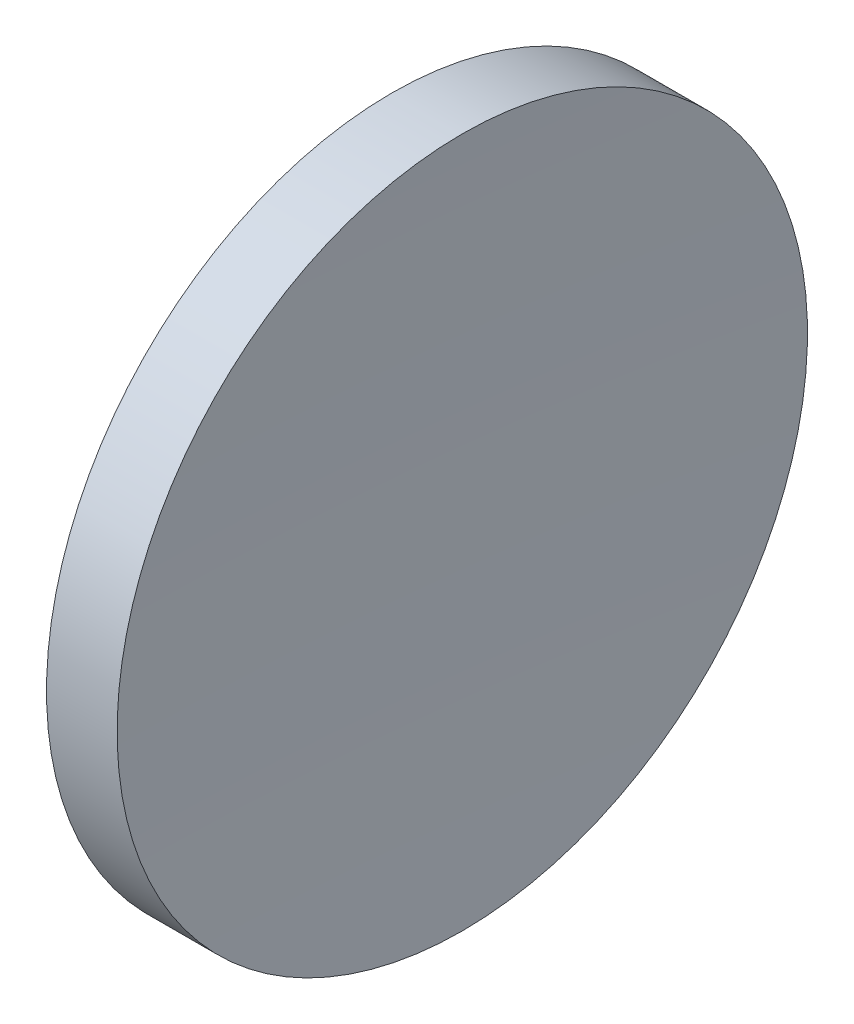
from build123d import *


with BuildPart() as part:
    # 草图1 → 旋转1 (revolve)
    with BuildSketch(Plane.XY):
        with BuildLine():
            Line((123.311924157, 77.716840471), (125.868954418, 77.716840471))
            ThreePointArc((125.868954418, 77.716840471), (125.676390648, 71.468158853), (125.612193698, 65.216840471))
            Line((125.612193698, 65.216840471), (122.612193698, 65.216840471))
            ThreePointArc((122.612193698, 65.216840471), (122.78726314, 71.476625266), (123.311924157, 77.716840471))
        make_face()
    revolve(axis=Axis((115.944491298, 65.216840471, 0), (1, 0, 0)))


solid = part.part
